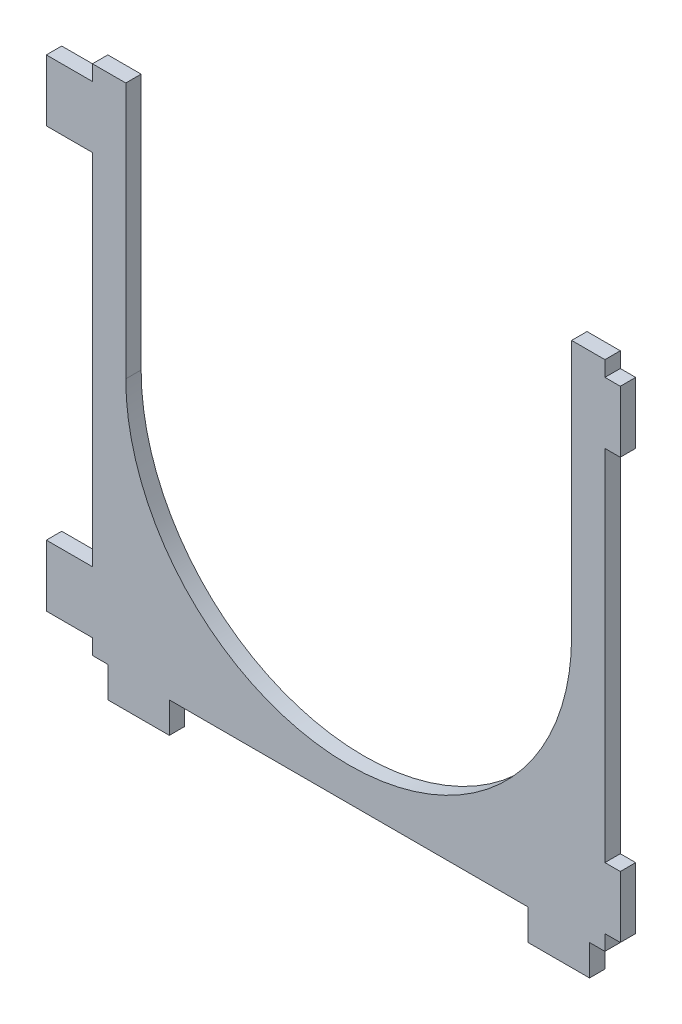
from build123d import *

# Parameters (mm, degrees)
CROQUIS1_W              = 100
CROQUIS1_H              = 100
CROQUIS1_R              = 43.5
SALIENTE_EXTRUIR1_DEPTH = 3
CROQUIS2_W              = 12
CROQUIS2_H              = 6
CROQUIS2_W_2            = 9
CROQUIS2_H_2            = 12
CROQUIS2_W_3            = 3
SALIENTE_EXTRUIR2_DEPTH = 3
CROQUIS3_W              = 87
CROQUIS3_H              = 50
CORTAR_EXTRUIR1_DEPTH   = 10


with BuildPart() as part:
    # Croquis1 → Saliente-Extruir1 (new body)
    with BuildSketch(Plane.XY):
        Rectangle(CROQUIS1_W, CROQUIS1_H)
        Circle(CROQUIS1_R, mode=Mode.SUBTRACT)
    extrude(amount=SALIENTE_EXTRUIR1_DEPTH)

    # Croquis2 → Saliente-Extruir2 (add)
    with BuildSketch(Plane.XY.offset(3)):
        with Locations((-41, -53)):
            Rectangle(CROQUIS2_W, CROQUIS2_H)
        with Locations((41, -53)):
            Rectangle(CROQUIS2_W, CROQUIS2_H)
        with Locations((-54.5, -41)):
            Rectangle(CROQUIS2_W_2, CROQUIS2_H_2)
        with Locations((51.5, -41)):
            Rectangle(CROQUIS2_W_3, CROQUIS2_H_2)
        with Locations((51.5, 41)):
            Rectangle(CROQUIS2_W_3, CROQUIS2_H_2)
        with Locations((-54.5, 41)):
            Rectangle(CROQUIS2_W_2, CROQUIS2_H_2)
    extrude(amount=-SALIENTE_EXTRUIR2_DEPTH)

    # Croquis3 → Cortar-Extruir1 (cut)
    with BuildSketch(Plane.XY.offset(3)):
        with Locations((0, 25)):
            Rectangle(CROQUIS3_W, CROQUIS3_H)
    extrude(amount=-CORTAR_EXTRUIR1_DEPTH, mode=Mode.SUBTRACT)


solid = part.part
